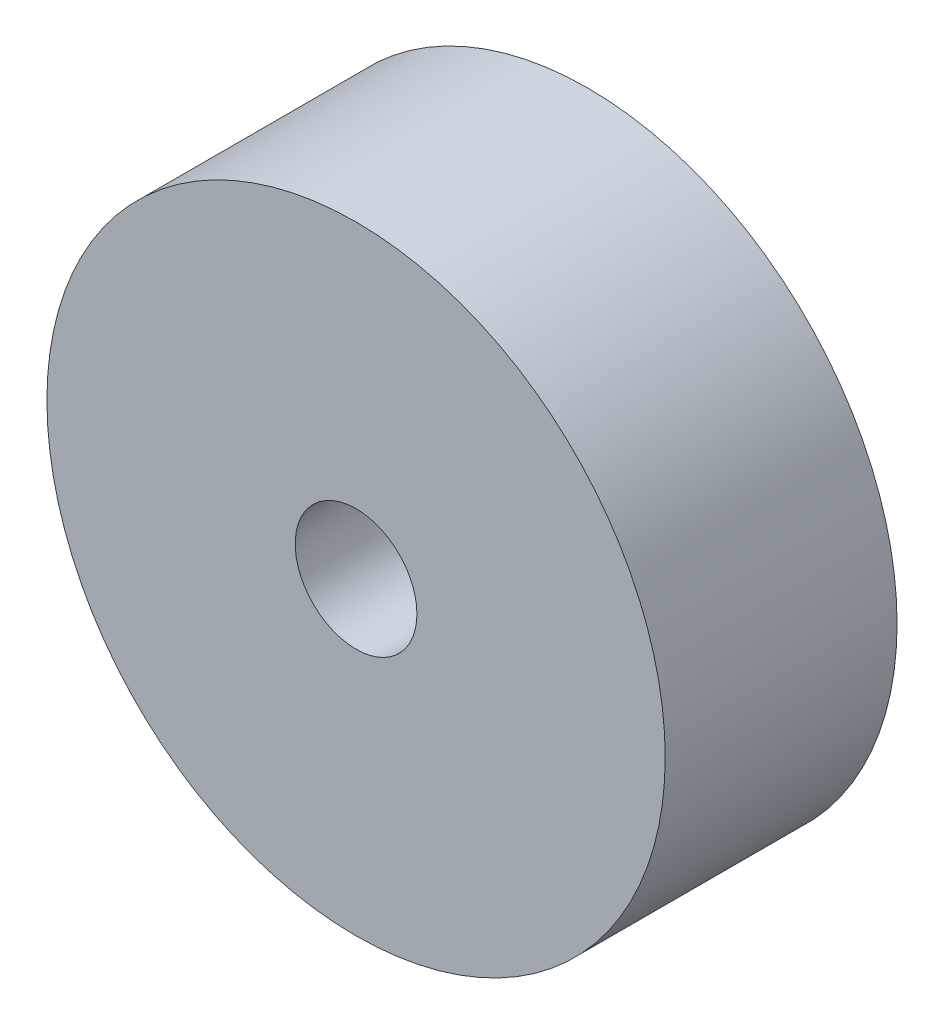
from build123d import *

# Parameters (mm, degrees)
SKETCH1_R           = 25.4
SKETCH1_R_2         = 5
BOSS_EXTRUDE1_DEPTH = 9.525


with BuildPart() as part:
    # Sketch1 → Boss-Extrude1 (new body, symmetric)
    with BuildSketch(Plane.XY):
        Circle(SKETCH1_R)
        Circle(SKETCH1_R_2, mode=Mode.SUBTRACT)
    extrude(amount=BOSS_EXTRUDE1_DEPTH, both=True)


solid = part.part
